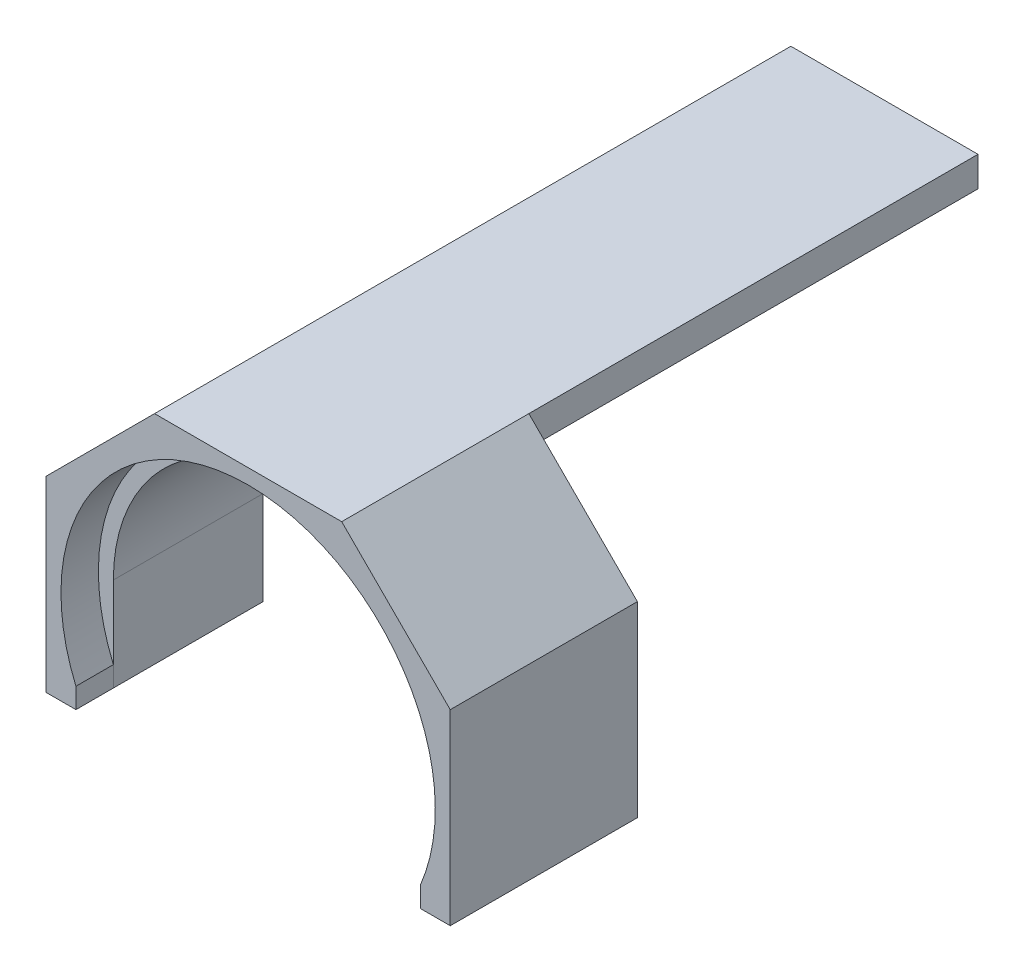
from build123d import *

# Parameters (mm, degrees)
SKETCH_1_W      = 50
SKETCH_1_H      = 8
EXTRUDE_1_DEPTH = 40
EXTRUDE_2_DEPTH = 10


with BuildPart() as part:
    # 扫描1: sweep along a path in 草图2
    with BuildLine(Plane(origin=(0, 0, 0), x_dir=(0, 0, -1), z_dir=(1, 0, 0))) as sweep_1_path:
        Line((0, 55.298323556), (-160, 55.298323556))
    # 草图1 → 扫描1 (sweep)
    with BuildSketch(Plane.XY):
        Rectangle(SKETCH_1_W, SKETCH_1_H)
    sweep(path=sweep_1_path.line)

    # 草图4 → 凸台-拉伸1 (add)
    with BuildSketch(Plane.XY.offset(160)):
        with BuildLine():
            Line((-54, -25), (-25, 4))
            Line((-25, 4), (25, 4))
            Line((25, 4), (54, -25))
            Line((54, -25), (54, -75))
            Line((54, -75), (46, -75))
            Line((46, -75), (46, -50))
            ThreePointArc((46, -50), (0, -4), (-46, -50))
            Line((-46, -50), (-46, -75))
            Line((-46, -75), (-54, -75))
            Line((-54, -75), (-54, -25))
        make_face()
    extrude(amount=-EXTRUDE_1_DEPTH)

    # 草图5 → 凸台-拉伸2 (add)
    with BuildSketch(Plane.XY.offset(160)):
        with BuildLine():
            Line((-46.0046646, -69.584964515), (-46, -75))
            Line((-46, -75), (-54, -75))
            Line((-54, -75), (-54, -25))
            Line((-54, -25), (-25, 4))
            Line((-25, 4), (25, 4))
            Line((25, 4), (54, -25))
            Line((54, -25), (54, -75))
            Line((54, -75), (46, -75))
            Line((46, -75), (46, -69.595917942))
            ThreePointArc((46, -69.595917942), (0.005952648, -3.54e-07), (-46.0046646, -69.584964515))
        make_face()
    extrude(amount=EXTRUDE_2_DEPTH)


solid = part.part
